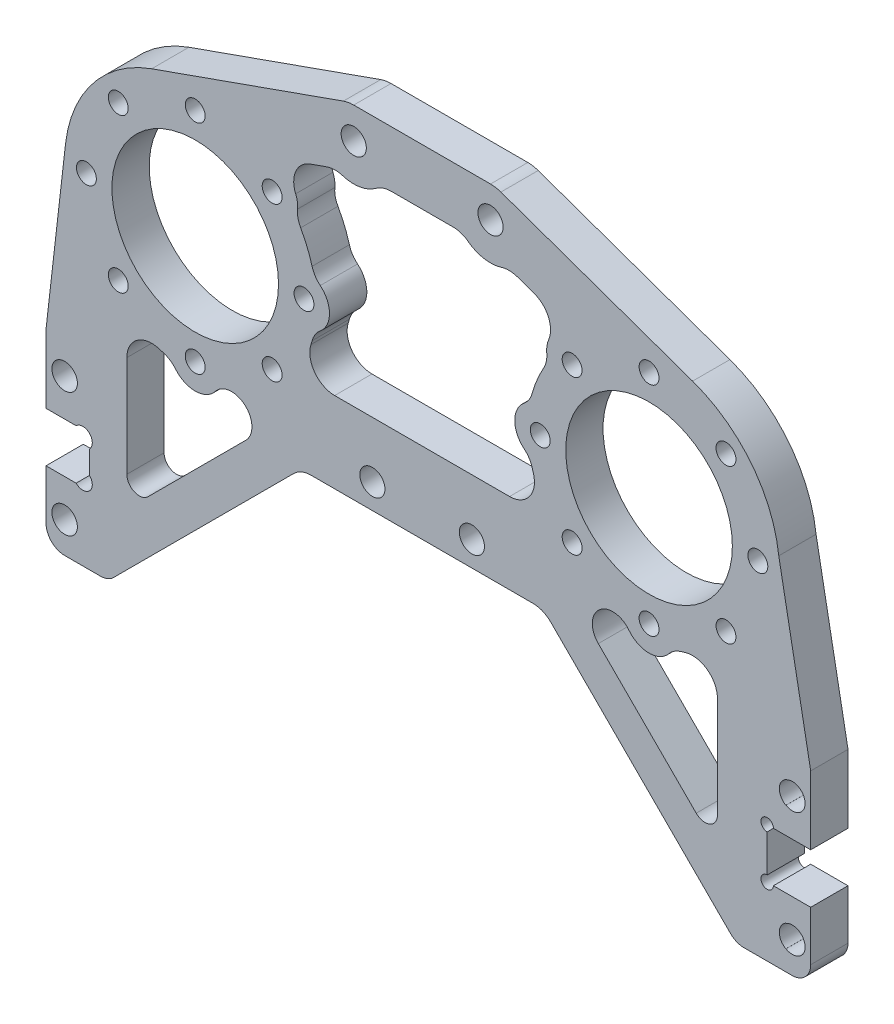
from build123d import *

# Parameters (mm, degrees)
SKETCH_1_R          = 2.025
SKETCH_1_R_2        = 13.4
SKETCH_1_R_3        = 1.6
EXTRUDE_1_DEPTH     = 6
CHAMFER_1_SIZE      = 2.2
SKETCH_2_R          = 2.05
EXTRUDE_1_2_DEPTH   = 6
CUT_EXTRUDE_2_DEPTH = 7
SKETCH_4_R          = 1.525
CUT_EXTRUDE_3_DEPTH = 7
FILLET_1_R          = 3
CUT_EXTRUDE_6_DEPTH = 7
SKETCH_10_R         = 2.05
EXTRUDE_2_DEPTH     = 6
SKETCH_11_R         = 2.05
SKETCH_11_R_2       = 1
CUT_EXTRUDE_8_DEPTH = 7


with BuildPart() as part:
    # 草图1 → Extrude 1 (new body)
    with BuildSketch(Plane.XY):
        with BuildLine():
            Line((-43.507889071, -19.796198897), (-12.668545017, -30.71338069))
            ThreePointArc((-12.668545017, -30.71338069), (-11.846491746, -30.927824238), (-11, -31))
            Line((-11, -31), (11, -31))
            ThreePointArc((11, -31), (11.846491746, -30.927824238), (12.668545017, -30.71338069))
            Line((12.668545017, -30.71338069), (43.507889071, -19.796198897))
            ThreePointArc((43.507889071, -19.796198897), (57.5, 0), (43.507889071, 19.796198897))
            Line((43.507889071, 19.796198897), (12.668545017, 30.71338069))
            ThreePointArc((12.668545017, 30.71338069), (11.846491746, 30.927824238), (11, 31))
            Line((11, 31), (-11, 31))
            ThreePointArc((-11, 31), (-11.846491746, 30.927824238), (-12.668545017, 30.71338069))
            Line((-12.668545017, 30.71338069), (-43.507889071, 19.796198897))
            ThreePointArc((-43.507889071, 19.796198897), (-57.5, 0), (-43.507889071, -19.796198897))
        make_face()
        with Locations((-11, 26)):
            Circle(SKETCH_1_R, mode=Mode.SUBTRACT)
        with Locations((11, 26)):
            Circle(SKETCH_1_R, mode=Mode.SUBTRACT)
        with Locations((-36.5, 0)):
            Circle(SKETCH_1_R_2, mode=Mode.SUBTRACT)
        with Locations((-19, 0)):
            Circle(SKETCH_1_R_3, mode=Mode.SUBTRACT)
        with Locations((-24.125631329, -12.374368671)):
            Circle(SKETCH_1_R_3, mode=Mode.SUBTRACT)
        with Locations((-36.5, -17.5)):
            Circle(SKETCH_1_R_3, mode=Mode.SUBTRACT)
        with Locations((-48.874368671, -12.374368671)):
            Circle(SKETCH_1_R_3, mode=Mode.SUBTRACT)
        with Locations((-54, 0)):
            Circle(SKETCH_1_R_3, mode=Mode.SUBTRACT)
        with Locations((-48.874368671, 12.374368671)):
            Circle(SKETCH_1_R_3, mode=Mode.SUBTRACT)
        with Locations((-36.5, 17.5)):
            Circle(SKETCH_1_R_3, mode=Mode.SUBTRACT)
        with Locations((-24.125631329, 12.374368671)):
            Circle(SKETCH_1_R_3, mode=Mode.SUBTRACT)
        with Locations((36.5, 0)):
            Circle(SKETCH_1_R_2, mode=Mode.SUBTRACT)
        with Locations((19, 0)):
            Circle(SKETCH_1_R_3, mode=Mode.SUBTRACT)
        with Locations((24.125631329, 12.374368671)):
            Circle(SKETCH_1_R_3, mode=Mode.SUBTRACT)
        with Locations((36.5, 17.5)):
            Circle(SKETCH_1_R_3, mode=Mode.SUBTRACT)
        with Locations((48.874368671, 12.374368671)):
            Circle(SKETCH_1_R_3, mode=Mode.SUBTRACT)
        with Locations((54, 0)):
            Circle(SKETCH_1_R_3, mode=Mode.SUBTRACT)
        with Locations((48.874368671, -12.374368671)):
            Circle(SKETCH_1_R_3, mode=Mode.SUBTRACT)
        with Locations((36.5, -17.5)):
            Circle(SKETCH_1_R_3, mode=Mode.SUBTRACT)
        with Locations((24.125631329, -12.374368671)):
            Circle(SKETCH_1_R_3, mode=Mode.SUBTRACT)
        with Locations((-8, -20)):
            Circle(SKETCH_1_R, mode=Mode.SUBTRACT)
        with Locations((8, -20)):
            Circle(SKETCH_1_R, mode=Mode.SUBTRACT)
    extrude(amount=EXTRUDE_1_DEPTH)

    # 倒角1
    chamfer_1_edges = [part.edges().sort_by_distance(p)[0] for p in [
        (-13.025, 26, 0),
        (8.975, 26, 0),
    ]]
    chamfer(chamfer_1_edges, length=CHAMFER_1_SIZE)

    # 草圖2 → Extrude 1 2 (add)
    with BuildSketch(Plane(origin=(0, 0, 0), x_dir=(-1, 0, 0), z_dir=(0, 0, -1))):
        with BuildLine():
            Line((60.5, -55), (0, -55))
            Line((0, -55), (0, -31))
            Line((0, -31), (43.507889071, -19.796198897))
            ThreePointArc((43.507889071, -19.796198897), (54.311590133, -11.124174439), (57.363656278, 2.389110027))
            Line((57.363656278, 2.389110027), (60.5, -24.999999992))
            Line((60.5, -24.999999992), (60.5, -35.999999996))
            Line((60.5, -35.999999996), (53.5, -35.999999996))
            Line((53.5, -35.999999996), (53.5, -43.999999996))
            Line((53.5, -43.999999996), (60.5, -43.999999996))
            Line((60.5, -43.999999996), (60.5, -55))
        make_face()
        with Locations((57.5, -29.999999996)):
            Circle(SKETCH_2_R, mode=Mode.SUBTRACT)
        with Locations((57.5, -49.999999996)):
            Circle(SKETCH_2_R, mode=Mode.SUBTRACT)
    extrude_1_2 = extrude(amount=-EXTRUDE_1_2_DEPTH)

    # 草图3 → 切除-拉伸2 (cut, through all)
    with BuildSketch(Plane(origin=(0, 0, 0), x_dir=(-1, 0, 0), z_dir=(0, 0, -1))):
        with BuildLine():
            Line((50.5, -55), (20.671572875, -25.171572875))
            ThreePointArc((20.671572875, -25.171572875), (19.37387948, -24.30448187), (17.843145751, -24))
            Line((17.843145751, -24), (0, -24))
            Line((0, -24), (0, -55))
            Line((0, -55), (50.5, -55))
        make_face()
    cut_extrude_2 = extrude(amount=-CUT_EXTRUDE_2_DEPTH, mode=Mode.SUBTRACT)

    # 草图4 → 切除-拉伸3 (cut, through all)
    with BuildSketch(Plane(origin=(0, 0, 0), x_dir=(-1, 0, 0), z_dir=(0, 0, -1))):
        with Locations((54.578337841, -42.921662155)):
            Circle(SKETCH_4_R)
        with Locations((54.578337841, -37.078337837)):
            Circle(SKETCH_4_R)
    cut_extrude_3 = extrude(amount=-CUT_EXTRUDE_3_DEPTH, mode=Mode.SUBTRACT)

    # 鏡射2: Extrude 1 2, 切除-拉伸2, 切除-拉伸3 across plane
    add(extrude_1_2.mirror(Plane(origin=(0, 0, 0), x_dir=(0, 0, 1), z_dir=(1, 0, 0))))
    add(cut_extrude_2.mirror(Plane(origin=(0, 0, 0), x_dir=(0, 0, 1), z_dir=(1, 0, 0))), mode=Mode.SUBTRACT)
    add(cut_extrude_3.mirror(Plane(origin=(0, 0, 0), x_dir=(0, 0, 1), z_dir=(1, 0, 0))), mode=Mode.SUBTRACT)

    # 圆角1
    fillet_1_edges = [part.edges().sort_by_distance(p)[0] for p in [
        (-60.5, -55, 3),
        (-50.5, -55, 3),
        (60.5, -55, 3),
        (50.5, -55, 3),
    ]]
    fillet(fillet_1_edges, radius=FILLET_1_R)

    # 草图9 → 切除-拉伸6 (cut, through all)
    with BuildSketch(Plane(origin=(0, 0, 0), x_dir=(-1, 0, 0), z_dir=(0, 0, -1))):
        with BuildLine():
            Line((47.5, -38.686291501), (47.5, -22.433234274))
            ThreePointArc((47.5, -22.433234274), (45.870025586, -19.210971292), (42.308510638, -18.614811419))
            ThreePointArc((42.308510638, -18.614811419), (41.99756521, -18.709002559), (41.685093635, -18.798))
            ThreePointArc((41.685093635, -18.798), (40.572946608, -19.297500942), (39.662923531, -20.108814815))
            ThreePointArc((39.662923531, -20.108814815), (36.438317678, -21.599535985), (33.260020655, -20.01247564))
            ThreePointArc((33.260020655, -20.01247564), (28.487933079, -19.560886472), (28.337204639, -24.351923265))
            Line((28.337204639, -24.351923265), (44.085786438, -40.100505063))
            ThreePointArc((44.085786438, -40.100505063), (46.265366865, -40.534050566), (47.5, -38.686291501))
        make_face()
        with BuildLine():
            Line((-14.066765726, -11), (14.066765726, -11))
            ThreePointArc((14.066765726, -11), (17.289028708, -9.370025586), (17.885188581, -5.808510638))
            ThreePointArc((17.885188581, -5.808510638), (17.790997441, -5.49756521), (17.702, -5.185093635))
            ThreePointArc((17.702, -5.185093635), (17.202499058, -4.072946608), (16.391185185, -3.162923531))
            ThreePointArc((16.391185185, -3.162923531), (14.9, 0), (16.391185185, 3.162923531))
            ThreePointArc((16.391185185, 3.162923531), (17.202499058, 4.072946608), (17.702, 5.185093635))
            ThreePointArc((17.702, 5.185093635), (18.484349116, 7.462326931), (19.541391857, 9.625778403))
            ThreePointArc((19.541391857, 9.625778403), (19.974598058, 10.76538561), (20.044396006, 11.98255464))
            ThreePointArc((20.044396006, 11.98255464), (20.072251251, 12.990899237), (20.345463726, 13.961924305))
            ThreePointArc((20.345463726, 13.961924305), (20.315570737, 17.128932218), (17.992331346, 19.281463622))
            Line((17.992331346, 19.281463622), (15.321220814, 20.227041428))
            ThreePointArc((15.321220814, 20.227041428), (14.060319956, 20.455653517), (12.79183088, 20.273802126))
            ThreePointArc((12.79183088, 20.273802126), (9.984209905, 20.086610914), (7.4, 21.2))
            ThreePointArc((7.4, 21.2), (6.264911064, 21.794733192), (5, 22))
            Line((5, 22), (-5, 22))
            ThreePointArc((-5, 22), (-6.264911064, 21.794733192), (-7.4, 21.2))
            ThreePointArc((-7.4, 21.2), (-9.984209905, 20.086610914), (-12.79183088, 20.273802126))
            ThreePointArc((-12.79183088, 20.273802126), (-14.060319956, 20.455653517), (-15.321220814, 20.227041428))
            Line((-15.321220814, 20.227041428), (-17.992331346, 19.281463622))
            ThreePointArc((-17.992331346, 19.281463622), (-20.315570737, 17.128932218), (-20.345463726, 13.961924305))
            ThreePointArc((-20.345463726, 13.961924305), (-20.072251251, 12.990899237), (-20.044396006, 11.98255464))
            ThreePointArc((-20.044396006, 11.98255464), (-19.974598058, 10.76538561), (-19.541391857, 9.625778403))
            ThreePointArc((-19.541391857, 9.625778403), (-18.484349116, 7.462326931), (-17.702, 5.185093635))
            ThreePointArc((-17.702, 5.185093635), (-17.202499058, 4.072946608), (-16.391185185, 3.162923531))
            ThreePointArc((-16.391185185, 3.162923531), (-14.9, 0), (-16.391185185, -3.162923531))
            ThreePointArc((-16.391185185, -3.162923531), (-17.202499058, -4.072946608), (-17.702, -5.185093635))
            ThreePointArc((-17.702, -5.185093635), (-17.790997441, -5.49756521), (-17.885188581, -5.808510638))
            ThreePointArc((-17.885188581, -5.808510638), (-17.289028708, -9.370025586), (-14.066765726, -11))
        make_face()
        with BuildLine():
            Line((-28.337204639, -24.351923265), (-44.085786438, -40.100505063))
            ThreePointArc((-44.085786438, -40.100505063), (-46.265366865, -40.534050566), (-47.5, -38.686291501))
            Line((-47.5, -38.686291501), (-47.5, -22.433234274))
            ThreePointArc((-47.5, -22.433234274), (-45.870025586, -19.210971292), (-42.308510638, -18.614811419))
            ThreePointArc((-42.308510638, -18.614811419), (-41.99756521, -18.709002559), (-41.685093635, -18.798))
            ThreePointArc((-41.685093635, -18.798), (-40.572946608, -19.297500942), (-39.662923531, -20.108814815))
            ThreePointArc((-39.662923531, -20.108814815), (-36.438317678, -21.599535985), (-33.260020655, -20.01247564))
            ThreePointArc((-33.260020655, -20.01247564), (-28.487933079, -19.560886472), (-28.337204639, -24.351923265))
        make_face()
    extrude(amount=-CUT_EXTRUDE_6_DEPTH, mode=Mode.SUBTRACT)

    # 草图10 → 凸台-拉伸2 (add)
    with BuildSketch(Plane(origin=(0, 0, 0), x_dir=(-1, 0, 0), z_dir=(0, 0, -1))):
        with BuildLine():
            Line((-62.5, -43.999999996), (-57.656675683, -43.999999996))
            Line((-57.656675683, -43.999999996), (-55.5, -43.999999996))
            Line((-55.5, -43.999999996), (-55.5, -35.999999996))
            Line((-55.5, -35.999999996), (-57.5, -35.999999996))
            Line((-57.5, -35.999999996), (-62.5, -35.999999996))
            Line((-62.5, -35.999999996), (-62.5, -24.999999992))
            Line((-62.5, -24.999999992), (-57.363656278, 2.389110027))
            Line((-57.363656278, 2.389110027), (-51.742640687, -24.999999992))
            Line((-51.742640687, -24.999999992), (-51.742640687, -55))
            Line((-51.742640687, -55), (-59.5, -55))
            ThreePointArc((-59.5, -55), (-61.621320344, -54.121320344), (-62.5, -52))
            Line((-62.5, -52), (-62.5, -43.999999996))
        make_face()
        with Locations((-59.5, -29.999999996)):
            Circle(SKETCH_10_R, mode=Mode.SUBTRACT)
        with Locations((-59.5, -49.999999996)):
            Circle(SKETCH_10_R, mode=Mode.SUBTRACT)
    extrude(amount=-EXTRUDE_2_DEPTH)

    # 草图11 → 切除-拉伸8 (cut, through all)
    with BuildSketch(Plane.XY):
        with Locations((59.55, -29.999999996)):
            Circle(SKETCH_11_R)
        with Locations((59.55, -49.999999996)):
            Circle(SKETCH_11_R)
        with Locations((55.5, -35.999999996)):
            Circle(SKETCH_11_R_2)
        with Locations((55.5, -43.999999996)):
            Circle(SKETCH_11_R_2)
    extrude(amount=CUT_EXTRUDE_8_DEPTH, mode=Mode.SUBTRACT)


solid = part.part
